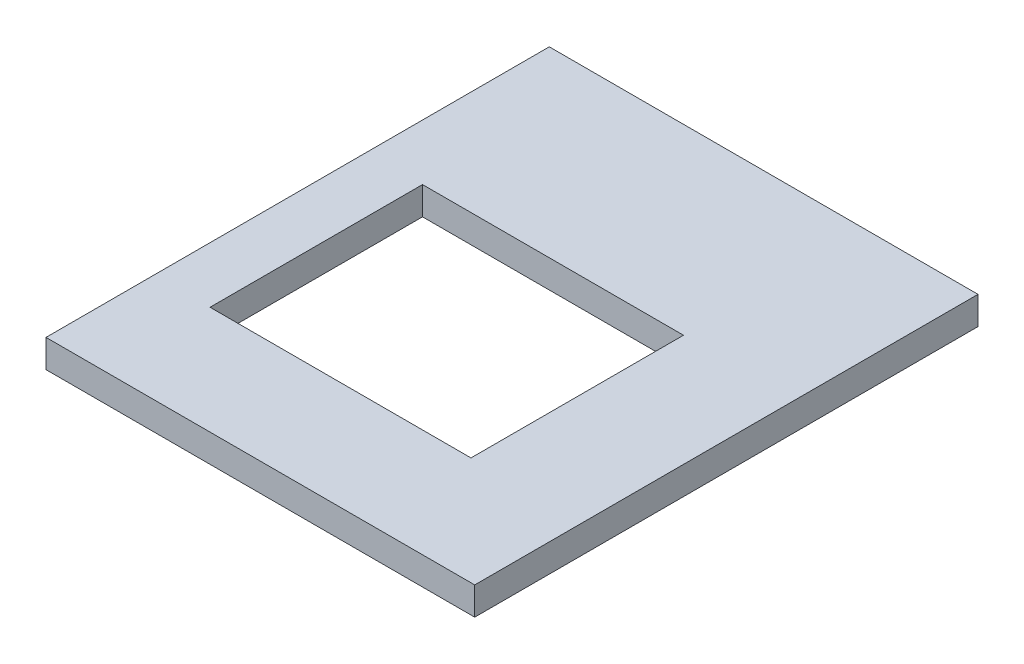
from build123d import *

# Parameters (mm, degrees)
ESBO_O1_W                = 2300
ESBO_O1_H                = 150
RESSALTO_EXTRUS_O1_DEPTH = 2700
ESBO_O2_W                = 1400
ESBO_O2_H                = 1140
CORTE_EXTRUS_O1_DEPTH    = 151


with BuildPart() as part:
    # Esboço1 → Ressalto-extrusão1 (new body)
    with BuildSketch(Plane.XY):
        with Locations((1150, 75)):
            Rectangle(ESBO_O1_W, ESBO_O1_H)
    extrude(amount=RESSALTO_EXTRUS_O1_DEPTH)

    # Esboço2 → Corte-extrusão1 (cut, through all)
    with BuildSketch(Plane(origin=(0, 150, 0), x_dir=(1, 0, 0), z_dir=(0, 1, 0))):
        with Locations((1000, -1550)):
            Rectangle(ESBO_O2_W, ESBO_O2_H)
    extrude(amount=-CORTE_EXTRUS_O1_DEPTH, mode=Mode.SUBTRACT)


solid = part.part
